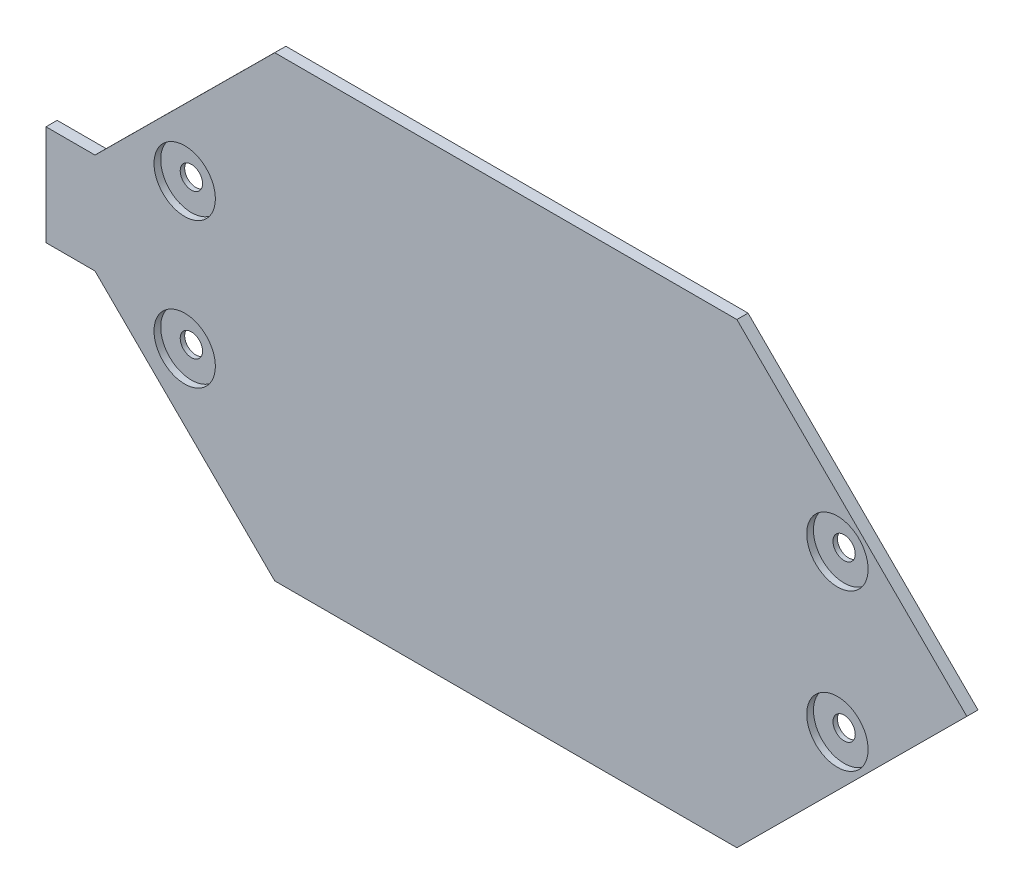
from build123d import *

# Parameters (mm, degrees)
SKETCH2_R           = 1
BOSS_EXTRUDE1_DEPTH = 1
CUT_EXTRUDE1_START  = 1
SKETCH3_R           = 2.75
CUT_EXTRUDE1_DEPTH  = 0.6


with BuildPart() as part:
    # Sketch2 → Boss-Extrude1 (new body)
    with BuildSketch(Plane.XY):
        Polygon((16.46, 48.53), (32.57, 32.53), (73.99, 32.53), (94.6, 53.03), (73.99, 73.53), (32.57, 73.53), (16.46, 57.53), (12.07, 57.53), (12.07, 48.53), align=None)
        with Locations((24.5, 59.53)):
            Circle(SKETCH2_R, mode=Mode.SUBTRACT)
        with Locations((24.5, 46.53)):
            Circle(SKETCH2_R, mode=Mode.SUBTRACT)
        with Locations((83, 60.03)):
            Circle(SKETCH2_R, mode=Mode.SUBTRACT)
        with Locations((83, 46.03)):
            Circle(SKETCH2_R, mode=Mode.SUBTRACT)
    extrude(amount=BOSS_EXTRUDE1_DEPTH)

    # Sketch3 → Cut-Extrude1 (cut)
    with BuildSketch(Plane.XY.offset(CUT_EXTRUDE1_START)):
        with Locations((24.5, 59.53)):
            Circle(SKETCH3_R)
        with Locations((24.5, 46.53)):
            Circle(SKETCH3_R)
        with Locations((83, 60.03)):
            Circle(SKETCH3_R)
        with Locations((83, 46.03)):
            Circle(SKETCH3_R)
    extrude(amount=-CUT_EXTRUDE1_DEPTH, mode=Mode.SUBTRACT)


solid = part.part
